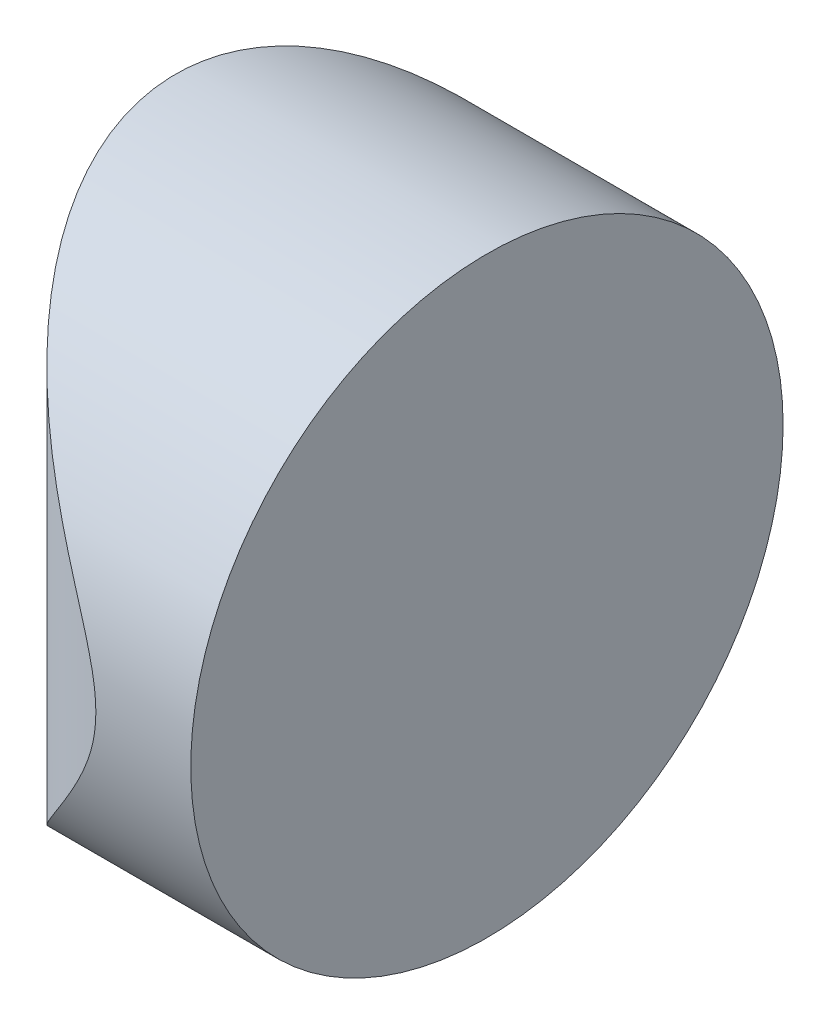
from build123d import *

# Parameters (mm, degrees)
EXTRUDE_1_DEPTH     = 12.5
CUT_EXTRUDE_8_DEPTH = 12.7


with BuildPart() as part:
    # 草图1 → 凸台-拉伸1 (new body)
    with BuildSketch(Plane(origin=(0, 0, 0), x_dir=(1, 0, 0), z_dir=(0, 1, 0))):
        with BuildLine():
            Line((2.362442432, 6.25), (4.365204335, 6.25))
            Line((4.365204335, 6.25), (4.365204335, -6.25))
            Line((4.365204335, -6.25), (2.362442432, -6.25))
            ThreePointArc((2.362442432, -6.25), (-2.204795665, 0), (2.362442432, 6.25))
        make_face()
    extrude(amount=EXTRUDE_1_DEPTH)

    # 草图2 → 切除-拉伸8 (cut)
    with BuildSketch(Plane(origin=(4.365204335, 0, 0), x_dir=(0, 0, -1), z_dir=(1, 0, 0))):
        with BuildLine():
            Line((-6.25, 12.5), (-6.25, 6.25))
            ThreePointArc((-6.25, 6.25), (-4.419417382, 10.669417382), (0, 12.5))
            Line((0, 12.5), (-6.25, 12.5))
        make_face()
        with BuildLine():
            ThreePointArc((0, 12.5), (4.419417382, 10.669417382), (6.25, 6.25))
            Line((6.25, 6.25), (6.25, 12.5))
            Line((6.25, 12.5), (0, 12.5))
        make_face()
        with BuildLine():
            ThreePointArc((6.25, 6.25), (4.419417382, 1.830582618), (0, 0))
            Line((0, 0), (6.25, 0))
            Line((6.25, 0), (6.25, 6.25))
        make_face()
        with BuildLine():
            Line((-6.25, 6.25), (-6.25, 0))
            Line((-6.25, 0), (0, 0))
            ThreePointArc((0, 0), (-4.419417382, 1.830582618), (-6.25, 6.25))
        make_face()
    extrude(amount=-CUT_EXTRUDE_8_DEPTH, mode=Mode.SUBTRACT)


solid = part.part
